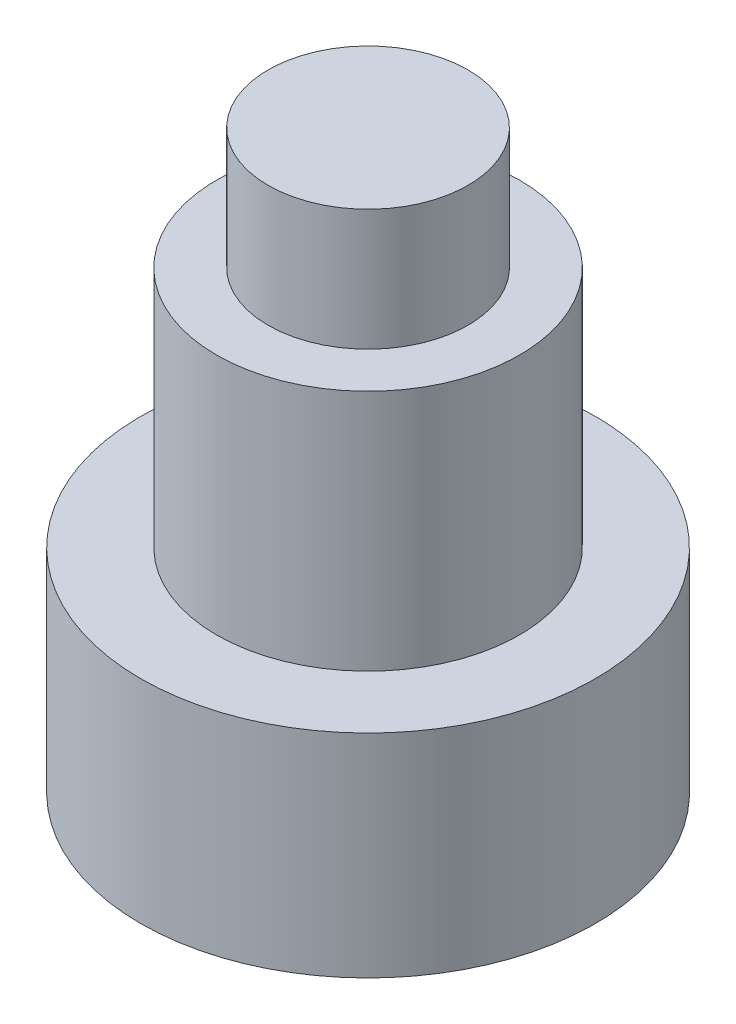
from build123d import *

# Parameters (mm, degrees)
SKETCH1_R           = 3.75
BOSS_EXTRUDE1_DEPTH = 7.5
SKETCH2_R           = 3.75
SKETCH2_R_2         = 2.5
CUT_EXTRUDE1_DEPTH  = 4
SKETCH3_R           = 1.65
BOSS_EXTRUDE2_DEPTH = 2


with BuildPart() as part:
    # Sketch1 → Boss-Extrude1 (new body)
    with BuildSketch(Plane(origin=(0, 0, 0), x_dir=(1, 0, 0), z_dir=(0, 1, 0))):
        Circle(SKETCH1_R)
    extrude(amount=BOSS_EXTRUDE1_DEPTH)

    # Sketch2 → Cut-Extrude1 (cut)
    with BuildSketch(Plane(origin=(0, 7.5, 0), x_dir=(1, 0, 0), z_dir=(0, 1, 0))):
        Circle(SKETCH2_R)
        Circle(SKETCH2_R_2, mode=Mode.SUBTRACT)
    extrude(amount=-CUT_EXTRUDE1_DEPTH, mode=Mode.SUBTRACT)

    # Sketch3 → Boss-Extrude2 (add)
    with BuildSketch(Plane(origin=(0, 7.5, 0), x_dir=(1, 0, 0), z_dir=(0, 1, 0))):
        Circle(SKETCH3_R)
    extrude(amount=BOSS_EXTRUDE2_DEPTH)


solid = part.part
